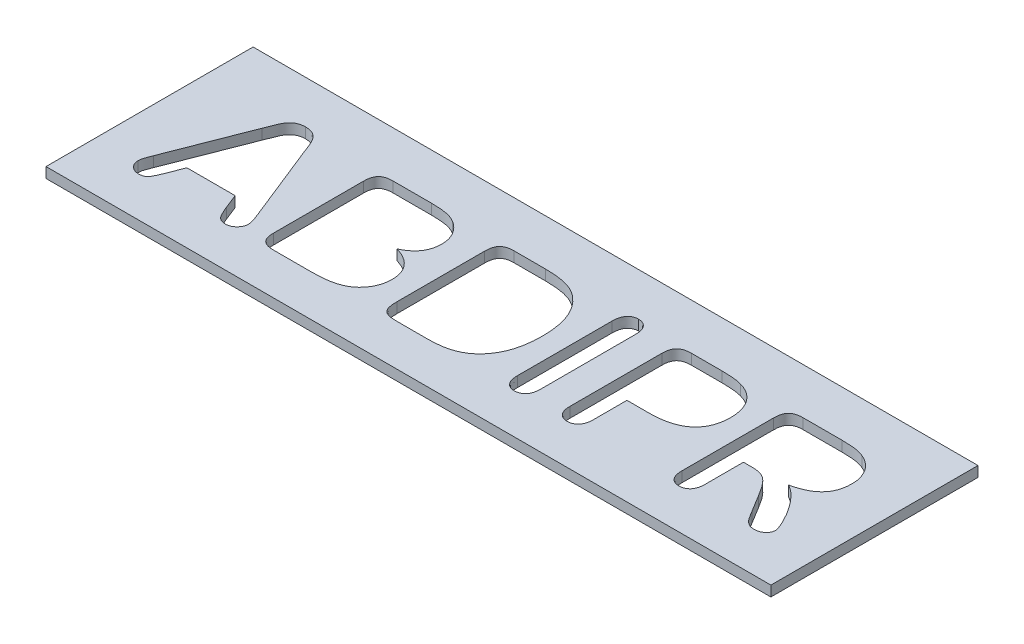
from build123d import *

# Parameters (mm, degrees)
SKETCH1_W           = 35
SKETCH1_H           = 10
BOSS_EXTRUDE1_DEPTH = 0.5
CUT_EXTRUDE4_DEPTH  = 2


with BuildPart() as part:
    # Sketch1 → Boss-Extrude1 (new body)
    with BuildSketch(Plane(origin=(0, 0, 0), x_dir=(1, 0, 0), z_dir=(0, 1, 0))):
        Rectangle(SKETCH1_W, SKETCH1_H)
    extrude(amount=BOSS_EXTRUDE1_DEPTH)

    # Sketch3 → Cut-Extrude4 (cut)
    with BuildSketch(Plane(origin=(0, 0.5, 0), x_dir=(1, 0, 0), z_dir=(0, 1, 0))):
        with BuildLine():
            Line((-11.441015625, -2.349609375), (-11.715234375, -1.65))
            Line((-11.715234375, -1.65), (-14.0484375, -1.65))
            Line((-14.0484375, -1.65), (-14.32265625, -2.36484375))
            add(Edge.make_bspline(
                [(-14.32265625, -2.36484375), (-14.347835962, -2.429152255), (-14.393986303, -2.547019345), (-14.465517251, -2.705100133), (-14.530354862, -2.829674932), (-14.59047857, -2.926424451), (-14.660607879, -2.997756493), (-14.748545347, -3.043456515), (-14.853497882, -3.070371804), (-14.929116363, -3.073387981), (-14.96953125, -3.075)],
                knots=[0, 0, 0, 0, 0.000207167, 0.000379703, 0.000520191, 0.000628424, 0.000720406, 0.000816364, 0.00092182, 0.001042887, 0.001042887, 0.001042887, 0.001042887], degree=3))
            add(Edge.make_bspline(
                [(-14.96953125, -3.075), (-15.005312309, -3.072983598), (-15.075874133, -3.069007165), (-15.177866168, -3.036727284), (-15.273080921, -2.985249355), (-15.359460508, -2.915667549), (-15.432410746, -2.833500255), (-15.485274497, -2.742148574), (-15.519177587, -2.645309748), (-15.52305102, -2.578005721), (-15.525, -2.544140625)],
                knots=[0, 0, 0, 0, 0.000107161, 0.000211326, 0.00031776, 0.000430315, 0.00054243, 0.000645342, 0.000745398, 0.00084673, 0.00084673, 0.00084673, 0.00084673], degree=3))
            add(Edge.make_bspline(
                [(-15.525, -2.544140625), (-15.523193689, -2.503741289), (-15.519483191, -2.420753523), (-15.493089704, -2.316105591), (-15.461401167, -2.225629232), (-15.432122251, -2.143573309), (-15.397345548, -2.048738896), (-15.370506217, -1.981956896), (-15.35625, -1.946484375)],
                knots=[0, 0, 0, 0, 0.000121067, 0.000248693, 0.000321699, 0.000408804, 0.000510028, 0.00062471, 0.00062471, 0.00062471, 0.00062471], degree=3))
            Line((-15.35625, -1.946484375), (-13.887890625, 1.82109375))
            add(Edge.make_bspline(
                [(-13.887890625, 1.82109375), (-13.877033183, 1.849640427), (-13.854390814, 1.909172349), (-13.81718647, 2.002041188), (-13.779422608, 2.103716802), (-13.737887875, 2.210452438), (-13.695622927, 2.317352773), (-13.648036449, 2.416388897), (-13.602120299, 2.507310579), (-13.552270206, 2.588270224), (-13.49796298, 2.661372403), (-13.43572884, 2.725938743), (-13.3651987, 2.782594974), (-13.287981265, 2.833809847), (-13.200946539, 2.874891932), (-13.104314819, 2.90434525), (-12.998298587, 2.921934285), (-12.924288276, 2.923953619), (-12.8859375, 2.925)],
                knots=[0, 0, 0, 0, 9.1624e-05, 0.000191075, 0.000300116, 0.00041698, 0.000534712, 0.000644799, 0.000746483, 0.000840145, 0.000929676, 0.001019185, 0.001108317, 0.001200627, 0.001296557, 0.001395897, 0.00150282, 0.001617813, 0.001617813, 0.001617813, 0.001617813], degree=3))
            add(Edge.make_bspline(
                [(-12.8859375, 2.925), (-12.847191426, 2.923964252), (-12.772395624, 2.921964834), (-12.665292553, 2.904219346), (-12.567931136, 2.875501695), (-12.481665511, 2.833299239), (-12.403893228, 2.783573977), (-12.333122677, 2.727829245), (-12.271563961, 2.663396877), (-12.200252444, 2.568895574), (-12.123532789, 2.440826658), (-12.059347002, 2.302613175), (-12.012806287, 2.180972039), (-11.969275082, 2.076734824), (-11.924501628, 1.957068728), (-11.892603014, 1.87264561), (-11.87578125, 1.828125)],
                knots=[0, 0, 0, 0, 0.000116163, 0.000224243, 0.000324704, 0.000419575, 0.000511251, 0.000601295, 0.000689147, 0.000777745, 0.000956013, 0.001135834, 0.001234194, 0.001346701, 0.001474671, 0.001617453, 0.001617453, 0.001617453, 0.001617453], degree=3))
            Line((-11.87578125, 1.828125), (-10.37578125, -1.91484375))
            add(Edge.make_bspline(
                [(-10.37578125, -1.91484375), (-10.362069188, -1.94919831), (-10.335664466, -2.015353397), (-10.298319026, -2.110858221), (-10.270475505, -2.200435562), (-10.242779562, -2.281190367), (-10.225096723, -2.35601766), (-10.210418027, -2.422642639), (-10.201346416, -2.482167939), (-10.200431427, -2.519504684), (-10.2, -2.537109375)],
                knots=[0, 0, 0, 0, 0.000110982, 0.000213714, 0.000307471, 0.000392341, 0.000469649, 0.00053791, 0.000597075, 0.000649862, 0.000649862, 0.000649862, 0.000649862], degree=3))
            add(Edge.make_bspline(
                [(-10.2, -2.537109375), (-10.202155142, -2.570132184), (-10.206480473, -2.636408348), (-10.238168464, -2.733668106), (-10.293183658, -2.82468516), (-10.364464071, -2.910029077), (-10.450232948, -2.983212519), (-10.54839153, -3.036396381), (-10.654957368, -3.069176662), (-10.729456816, -3.07304225), (-10.7671875, -3.075)],
                knots=[0, 0, 0, 0, 9.9001e-05, 0.000198693, 0.000303207, 0.00041634, 0.000531124, 0.000639146, 0.000749259, 0.000862252, 0.000862252, 0.000862252, 0.000862252], degree=3))
            add(Edge.make_bspline(
                [(-10.7671875, -3.075), (-10.810045817, -3.073116816), (-10.890793668, -3.069568774), (-11.002453245, -3.033539946), (-11.093956784, -2.974673834), (-11.15863903, -2.911722548), (-11.203137979, -2.848941962), (-11.238148472, -2.791272681), (-11.274323764, -2.723100446), (-11.322497594, -2.62112411), (-11.37672123, -2.494818059), (-11.420622538, -2.395667095), (-11.441015625, -2.349609375)],
                knots=[0, 0, 0, 0, 0.000128271, 0.000241671, 0.000347009, 0.00045225, 0.000510148, 0.000577477, 0.000654545, 0.000741556, 0.000915752, 0.001066865, 0.001066865, 0.001066865, 0.001066865], degree=3))
        make_face()
        with BuildLine():
            Line((-6.75703125, -3), (-8.5171875, -3))
            add(Edge.make_bspline(
                [(-8.5171875, -3), (-8.548066158, -2.999684683), (-8.607211026, -2.999080726), (-8.692644647, -2.990770966), (-8.770947545, -2.976754729), (-8.842771247, -2.958217792), (-8.908089191, -2.93471954), (-8.96692833, -2.9061107), (-9.017782509, -2.869904795), (-9.07875055, -2.816360555), (-9.140301939, -2.729140438), (-9.189624937, -2.601657903), (-9.219877565, -2.450216486), (-9.223214212, -2.341173041), (-9.225, -2.2828125)],
                knots=[0, 0, 0, 0, 9.2608e-05, 0.000177381, 0.000257146, 0.000331048, 0.00039963, 0.00046514, 0.000526583, 0.000586337, 0.000707992, 0.000842042, 0.000993957, 0.001168885, 0.001168885, 0.001168885, 0.001168885], degree=3))
            Line((-9.225, -2.2828125), (-9.225, 2.0578125))
            add(Edge.make_bspline(
                [(-9.225, 2.0578125), (-9.223375416, 2.117371055), (-9.220355101, 2.228098226), (-9.188552092, 2.381042192), (-9.138305638, 2.508895247), (-9.062752389, 2.611877256), (-8.960932817, 2.687796753), (-8.834312538, 2.738830555), (-8.683927793, 2.770066267), (-8.575170639, 2.773284318), (-8.5171875, 2.775)],
                knots=[0, 0, 0, 0, 0.000178437, 0.000331738, 0.000466233, 0.00058764, 0.000709751, 0.000842085, 0.000994239, 0.001167997, 0.001167997, 0.001167997, 0.001167997], degree=3))
            Line((-8.5171875, 2.775), (-6.6515625, 2.775))
            add(Edge.make_bspline(
                [(-6.6515625, 2.775), (-6.585147608, 2.774247249), (-6.456546362, 2.772789674), (-6.270794249, 2.763868156), (-6.098739867, 2.74744078), (-5.939206601, 2.724758831), (-5.790298563, 2.691685935), (-5.649474707, 2.649197945), (-5.517714172, 2.591062773), (-5.435171158, 2.544064871), (-5.394140625, 2.520703125)],
                knots=[0, 0, 0, 0, 0.00019925, 0.000385814, 0.000557692, 0.000717622, 0.00086888, 0.001014918, 0.00115818, 0.001299778, 0.001299778, 0.001299778, 0.001299778], degree=3))
            add(Edge.make_bspline(
                [(-5.394140625, 2.520703125), (-5.360161211, 2.499396475), (-5.29220561, 2.456785199), (-5.197222519, 2.382645993), (-5.108971786, 2.299601488), (-5.026233579, 2.210306513), (-4.95099385, 2.114129902), (-4.885128336, 2.012316969), (-4.83023231, 1.904654916), (-4.783065612, 1.793232088), (-4.745153453, 1.677770503), (-4.720148205, 1.558227489), (-4.702342929, 1.436082227), (-4.701045751, 1.353191284), (-4.700390625, 1.311328125)],
                knots=[0, 0, 0, 0, 0.000120264, 0.000240517, 0.000360741, 0.000483481, 0.000605379, 0.000726627, 0.000846651, 0.000967445, 0.001089371, 0.001210505, 0.00133348, 0.001458958, 0.001458958, 0.001458958, 0.001458958], degree=3))
            add(Edge.make_bspline(
                [(-4.700390625, 1.311328125), (-4.702988671, 1.240796002), (-4.708044042, 1.103552116), (-4.750406113, 0.905273758), (-4.818338805, 0.720970725), (-4.915852756, 0.551862405), (-5.040552639, 0.397345857), (-5.194337126, 0.260072678), (-5.37373492, 0.13565648), (-5.50764742, 0.068658714), (-5.576953125, 0.033984375)],
                knots=[0, 0, 0, 0, 0.000211406, 0.000411361, 0.000605302, 0.000798476, 0.000994306, 0.001198394, 0.001414886, 0.001647125, 0.001647125, 0.001647125, 0.001647125], degree=3))
            add(Edge.make_bspline(
                [(-5.576953125, 0.033984375), (-5.530273502, 0.01850607), (-5.439172939, -0.011701592), (-5.308710293, -0.065060268), (-5.186483504, -0.121876895), (-5.073507124, -0.185143227), (-4.970263496, -0.254875067), (-4.874609675, -0.328273429), (-4.789067069, -0.408268175), (-4.712116337, -0.493263322), (-4.644210619, -0.58342165), (-4.584823142, -0.678896049), (-4.536232473, -0.780262552), (-4.493934136, -0.885899675), (-4.464826814, -0.998402007), (-4.440274592, -1.115100833), (-4.428038837, -1.23763197), (-4.42602398, -1.320682894), (-4.425, -1.362890625)],
                knots=[0, 0, 0, 0, 0.000147498, 0.000287859, 0.000422584, 0.000551661, 0.000675819, 0.000796071, 0.000912983, 0.001026655, 0.001139624, 0.001251174, 0.001363332, 0.001476495, 0.001591917, 0.001711426, 0.00183398, 0.00196063, 0.00196063, 0.00196063, 0.00196063], degree=3))
            add(Edge.make_bspline(
                [(-4.425, -1.362890625), (-4.427626881, -1.44089384), (-4.432814111, -1.594924682), (-4.483110744, -1.819042589), (-4.561780312, -2.031773243), (-4.672429347, -2.228892641), (-4.807833827, -2.408638341), (-4.967607701, -2.564839815), (-5.150016922, -2.696405243), (-5.285579599, -2.761004415), (-5.354296875, -2.79375)],
                knots=[0, 0, 0, 0, 0.0002337, 0.000461481, 0.00068546, 0.000912081, 0.001137084, 0.001358345, 0.001580123, 0.001808113, 0.001808113, 0.001808113, 0.001808113], degree=3))
            add(Edge.make_bspline(
                [(-5.354296875, -2.79375), (-5.399754504, -2.812000974), (-5.492589121, -2.849273534), (-5.639572751, -2.893494252), (-5.796443624, -2.92800838), (-5.963359802, -2.956604003), (-6.142283634, -2.975665677), (-6.334601684, -2.989341746), (-6.540910731, -2.999407091), (-6.683580759, -2.999798494), (-6.75703125, -3)],
                knots=[0, 0, 0, 0, 0.000146901, 0.000300005, 0.00045978, 0.000628546, 0.000807782, 0.000999314, 0.001206948, 0.001427273, 0.001427273, 0.001427273, 0.001427273], degree=3))
        make_face()
        with BuildLine():
            Line((-2.6859375, 2.775), (-1.147265625, 2.775))
            add(Edge.make_bspline(
                [(-1.147265625, 2.775), (-1.050750895, 2.77361917), (-0.864535134, 2.770954993), (-0.595997762, 2.751570127), (-0.349102986, 2.717452462), (-0.120663099, 2.671840852), (0.092500353, 2.605420148), (0.294335668, 2.517397132), (0.486016839, 2.404286593), (0.60295242, 2.311947915), (0.662109375, 2.265234375)],
                knots=[0, 0, 0, 0, 0.000289539, 0.000558636, 0.000807066, 0.001036896, 0.001256688, 0.001475506, 0.001696179, 0.001922117, 0.001922117, 0.001922117, 0.001922117], degree=3))
            add(Edge.make_bspline(
                [(0.662109375, 2.265234375), (0.699204557, 2.23204259), (0.773360626, 2.165689706), (0.877526546, 2.059236928), (0.97420917, 1.946074816), (1.063080409, 1.826413034), (1.145281744, 1.700806739), (1.220533689, 1.569000172), (1.28895067, 1.430736631), (1.347729443, 1.284821053), (1.402581568, 1.134012825), (1.447237326, 0.976216153), (1.488225883, 0.813191248), (1.518697841, 0.642687976), (1.545203145, 0.466575533), (1.562176311, 0.283861789), (1.573097822, 0.095057741), (1.574358547, -0.033186992), (1.575, -0.0984375)],
                knots=[0, 0, 0, 0, 0.000149303, 0.000298467, 0.000446421, 0.000595484, 0.000745324, 0.000896491, 0.001050574, 0.001207697, 0.001368192, 0.001531739, 0.001699432, 0.001872275, 0.002051096, 0.002233585, 0.002422552, 0.002618286, 0.002618286, 0.002618286, 0.002618286], degree=3))
            add(Edge.make_bspline(
                [(1.575, -0.0984375), (1.573794855, -0.184006161), (1.571442807, -0.351008177), (1.555405103, -0.596376388), (1.525887303, -0.829812399), (1.486384251, -1.052573716), (1.435093541, -1.264175052), (1.370915117, -1.464887332), (1.293061527, -1.654819682), (1.202701995, -1.834095171), (1.100629294, -2.004458553), (0.983405175, -2.163815899), (0.855141018, -2.31644177), (0.758700791, -2.408659192), (0.71015625, -2.455078125)],
                knots=[0, 0, 0, 0, 0.000256708, 0.000501009, 0.000737208, 0.000962248, 0.001179396, 0.001389897, 0.001593806, 0.001794529, 0.001991686, 0.002188816, 0.002387486, 0.002588847, 0.002588847, 0.002588847, 0.002588847], degree=3))
            add(Edge.make_bspline(
                [(0.71015625, -2.455078125), (0.670808323, -2.487756238), (0.59276456, -2.552570909), (0.46729574, -2.638086397), (0.337301324, -2.714845461), (0.200908362, -2.780164108), (0.059765152, -2.836294246), (-0.085968828, -2.884905991), (-0.237194539, -2.923298904), (-0.39419838, -2.95267784), (-0.558630516, -2.973282528), (-0.732193291, -2.98840301), (-0.916303006, -2.997859007), (-1.042566688, -2.999273465), (-1.107421875, -3)],
                knots=[0, 0, 0, 0, 0.000153368, 0.000304194, 0.000454934, 0.000605883, 0.000757341, 0.000910391, 0.001066431, 0.001225019, 0.00138927, 0.001563375, 0.001747599, 0.001942162, 0.001942162, 0.001942162, 0.001942162], degree=3))
            Line((-1.107421875, -3), (-2.633203125, -3))
            add(Edge.make_bspline(
                [(-2.633203125, -3), (-2.683293312, -2.999225047), (-2.77723658, -2.997771636), (-2.908251776, -2.978207976), (-3.020827368, -2.951188051), (-3.114131747, -2.908026317), (-3.189319084, -2.852952048), (-3.250458451, -2.788830509), (-3.297101361, -2.714732595), (-3.329030277, -2.629666887), (-3.348444949, -2.533803398), (-3.363873799, -2.426199575), (-3.372929583, -2.305618442), (-3.374287517, -2.220717744), (-3.375, -2.176171875)],
                knots=[0, 0, 0, 0, 0.000150114, 0.000281537, 0.000396655, 0.000496265, 0.000587679, 0.000674721, 0.000760557, 0.000848479, 0.000945716, 0.001053439, 0.001174506, 0.001308146, 0.001308146, 0.001308146, 0.001308146], degree=3))
            Line((-3.375, -2.176171875), (-3.375, 2.0578125))
            add(Edge.make_bspline(
                [(-3.375, 2.0578125), (-3.373208148, 2.11656741), (-3.369858826, 2.226391877), (-3.339719242, 2.378565117), (-3.29070443, 2.506457745), (-3.21653605, 2.608767051), (-3.117551938, 2.685414072), (-2.995036312, 2.73910011), (-2.847982054, 2.769962347), (-2.742343971, 2.773246431), (-2.6859375, 2.775)],
                knots=[0, 0, 0, 0, 0.000176097, 0.000329161, 0.000463211, 0.00058392, 0.00070325, 0.000834374, 0.000981947, 0.001151026, 0.001151026, 0.001151026, 0.001151026], degree=3))
        make_face()
        with BuildLine():
            Line((2.625, -2.358984375), (2.625, 2.2125))
            add(Edge.make_bspline(
                [(2.625, 2.2125), (2.626372257, 2.268534342), (2.628947099, 2.373674747), (2.65887973, 2.520292536), (2.705191012, 2.646298707), (2.775330907, 2.747864159), (2.858882217, 2.828196162), (2.956909337, 2.884115843), (3.065500905, 2.920066505), (3.142287861, 2.923328335), (3.181640625, 2.925)],
                knots=[0, 0, 0, 0, 0.00016784, 0.000314928, 0.000447023, 0.000567612, 0.000682013, 0.000791757, 0.000903681, 0.001021343, 0.001021343, 0.001021343, 0.001021343], degree=3))
            add(Edge.make_bspline(
                [(3.181640625, 2.925), (3.222162859, 2.923361853), (3.300865244, 2.920180241), (3.41214605, 2.88414904), (3.511943317, 2.82855475), (3.597693577, 2.74913551), (3.668158131, 2.647775576), (3.716893344, 2.522277833), (3.745841861, 2.374760553), (3.748554739, 2.268897544), (3.75, 2.2125)],
                knots=[0, 0, 0, 0, 0.000121163, 0.000235323, 0.000347101, 0.000461561, 0.000582815, 0.000714253, 0.000862489, 0.0010315, 0.0010315, 0.0010315, 0.0010315], degree=3))
            Line((3.75, 2.2125), (3.75, -2.358984375))
            add(Edge.make_bspline(
                [(3.75, -2.358984375), (3.748566282, -2.415383127), (3.745875072, -2.521248402), (3.716714134, -2.669108291), (3.668099781, -2.795271696), (3.598139431, -2.897981928), (3.511533961, -2.977024753), (3.412747746, -3.034810993), (3.300519327, -3.068262311), (3.222095717, -3.072707127), (3.181640625, -3.075)],
                knots=[0, 0, 0, 0, 0.00016901, 0.000317247, 0.000449772, 0.00057199, 0.000686451, 0.00079881, 0.000912627, 0.001033898, 0.001033898, 0.001033898, 0.001033898], degree=3))
            add(Edge.make_bspline(
                [(3.181640625, -3.075), (3.142749904, -3.07267064), (3.067019935, -3.068134792), (2.958513966, -3.034840225), (2.862545505, -2.975966407), (2.777305392, -2.89685328), (2.706176655, -2.794152097), (2.660632263, -2.666937475), (2.628451723, -2.520345529), (2.626199442, -2.415055894), (2.625, -2.358984375)],
                knots=[0, 0, 0, 0, 0.000116606, 0.000227061, 0.000336391, 0.000451647, 0.000573865, 0.000707052, 0.000854378, 0.001022218, 0.001022218, 0.001022218, 0.001022218], degree=3))
        make_face()
        with BuildLine():
            Line((7.359375, -0.75), (6.3, -0.75))
            Line((6.3, -0.75), (6.3, -2.368359375))
            add(Edge.make_bspline(
                [(6.3, -2.368359375), (6.29865037, -2.422834651), (6.296091572, -2.526115714), (6.2652422, -2.670183826), (6.216669575, -2.795106489), (6.145364996, -2.896517112), (6.059997751, -2.976407479), (5.963163888, -3.034522007), (5.854499391, -3.068193031), (5.77874633, -3.0726904), (5.73984375, -3.075)],
                knots=[0, 0, 0, 0, 0.00016316, 0.00030934, 0.000439692, 0.000562577, 0.000677832, 0.000788169, 0.000898624, 0.00101523, 0.00101523, 0.00101523, 0.00101523], degree=3))
            add(Edge.make_bspline(
                [(5.73984375, -3.075), (5.699400293, -3.072687248), (5.620999236, -3.068203896), (5.508937943, -3.035123568), (5.4109881, -2.976607828), (5.324815484, -2.898467898), (5.255941764, -2.796656723), (5.208699533, -2.672816611), (5.179213967, -2.529502753), (5.17645619, -2.427112203), (5.175, -2.373046875)],
                knots=[0, 0, 0, 0, 0.000121271, 0.000235087, 0.000346434, 0.000460895, 0.000581484, 0.000711398, 0.00085619, 0.00101818, 0.00101818, 0.00101818, 0.00101818], degree=3))
            Line((5.175, -2.373046875), (5.175, 2.061328125))
            add(Edge.make_bspline(
                [(5.175, 2.061328125), (5.175326, 2.09220632), (5.175954525, 2.15173923), (5.184245402, 2.237947887), (5.19814518, 2.31705589), (5.216762086, 2.38978201), (5.241059702, 2.455040586), (5.270780076, 2.513726999), (5.305784318, 2.565747457), (5.361797587, 2.626083745), (5.449096695, 2.689250897), (5.577875048, 2.739853278), (5.731051886, 2.76986248), (5.841252832, 2.773205835), (5.900390625, 2.775)],
                knots=[0, 0, 0, 0, 9.2608e-05, 0.000178547, 0.000259466, 0.000333368, 0.000403456, 0.00046792, 0.000530327, 0.000590869, 0.000714161, 0.000849739, 0.001002802, 0.00118007, 0.00118007, 0.00118007, 0.00118007], degree=3))
            Line((5.900390625, 2.775), (7.369921875, 2.775))
            add(Edge.make_bspline(
                [(7.369921875, 2.775), (7.422664023, 2.775010091), (7.525059934, 2.775029682), (7.67389829, 2.768466252), (7.813367698, 2.760337506), (7.943654943, 2.750601935), (8.064431442, 2.735243653), (8.175705348, 2.716216263), (8.278076971, 2.696041062), (8.34228087, 2.678119244), (8.373046875, 2.66953125)],
                knots=[0, 0, 0, 0, 0.000158207, 0.000307151, 0.000446845, 0.00057735, 0.000699011, 0.000811907, 0.000916019, 0.001011812, 0.001011812, 0.001011812, 0.001011812], degree=3))
            add(Edge.make_bspline(
                [(8.373046875, 2.66953125), (8.431373386, 2.651775877), (8.546114862, 2.61684703), (8.707380779, 2.541218339), (8.858062265, 2.452337636), (8.994731548, 2.345234583), (9.11799016, 2.224738583), (9.225960776, 2.090733108), (9.317803465, 1.943647039), (9.392092467, 1.783400112), (9.452798531, 1.613008843), (9.494072303, 1.431259277), (9.520933822, 1.239476645), (9.523624188, 1.107907437), (9.525, 1.040625)],
                knots=[0, 0, 0, 0, 0.000182696, 0.000359405, 0.000532846, 0.000706545, 0.00087891, 0.001048933, 0.001221596, 0.001397737, 0.001577863, 0.001763197, 0.001955944, 0.002157674, 0.002157674, 0.002157674, 0.002157674], degree=3))
            add(Edge.make_bspline(
                [(9.525, 1.040625), (9.523639944, 0.969441406), (9.520992452, 0.830875104), (9.494270667, 0.62970649), (9.453125864, 0.441306934), (9.39297871, 0.266296959), (9.315551283, 0.104972014), (9.220902953, -0.042832746), (9.109921711, -0.177754192), (8.98145365, -0.298843797), (8.836103572, -0.405856207), (8.674464805, -0.499348035), (8.494831071, -0.575599183), (8.299940545, -0.640791532), (8.087750438, -0.688685124), (7.860062704, -0.725424075), (7.615229659, -0.746190147), (7.446522436, -0.748702314), (7.359375, -0.75)],
                knots=[0, 0, 0, 0, 0.000213439, 0.000415481, 0.000607669, 0.000791115, 0.000969321, 0.001143237, 0.001316389, 0.001492131, 0.001671432, 0.001856759, 0.002050951, 0.002255881, 0.002472485, 0.002702713, 0.002947374, 0.003208797, 0.003208797, 0.003208797, 0.003208797], degree=3))
        make_face()
        with BuildLine():
            Line((12.10546875, -0.525), (11.7, -0.525))
            Line((11.7, -0.525), (11.7, -2.3671875))
            add(Edge.make_bspline(
                [(11.7, -2.3671875), (11.698572444, -2.423972464), (11.695901407, -2.530220255), (11.666941387, -2.678184043), (11.618204871, -2.802976511), (11.549336018, -2.90393262), (11.463990524, -2.980416024), (11.366621919, -3.035790544), (11.256882965, -3.069690448), (11.179539779, -3.073199166), (11.13984375, -3.075)],
                knots=[0, 0, 0, 0, 0.00017018, 0.000318417, 0.000449855, 0.000569478, 0.000681495, 0.000790655, 0.000903351, 0.001022179, 0.001022179, 0.001022179, 0.001022179], degree=3))
            add(Edge.make_bspline(
                [(11.13984375, -3.075), (11.097419425, -3.072847061), (11.015769314, -3.068703501), (10.900783826, -3.034322246), (10.801478575, -2.976118471), (10.717621239, -2.896018404), (10.65254807, -2.792486711), (10.60773047, -2.667792628), (10.579406988, -2.52313387), (10.576526661, -2.419678338), (10.575, -2.36484375)],
                knots=[0, 0, 0, 0, 0.000127104, 0.000244625, 0.000355972, 0.000469523, 0.000589151, 0.000719314, 0.000865023, 0.001029353, 0.001029353, 0.001029353, 0.001029353], degree=3))
            Line((10.575, -2.36484375), (10.575, 2.061328125))
            add(Edge.make_bspline(
                [(10.575, 2.061328125), (10.576717433, 2.119700782), (10.579939967, 2.229229306), (10.611185323, 2.380758993), (10.661991643, 2.508002941), (10.737132998, 2.610363541), (10.838271675, 2.686760864), (10.963899667, 2.7389316), (11.114124036, 2.770093303), (11.22249019, 2.773289797), (11.28046875, 2.775)],
                knots=[0, 0, 0, 0, 0.000174928, 0.000328228, 0.000461642, 0.000583049, 0.000704229, 0.000837023, 0.000988032, 0.001161789, 0.001161789, 0.001161789, 0.001161789], degree=3))
            Line((11.28046875, 2.775), (13.15078125, 2.775))
            add(Edge.make_bspline(
                [(13.15078125, 2.775), (13.21289178, 2.774430966), (13.332453914, 2.773335582), (13.50526269, 2.768342035), (13.663881101, 2.75614996), (13.81016602, 2.74123347), (13.946041381, 2.721250507), (14.073420863, 2.689764053), (14.19478395, 2.652351796), (14.27099611, 2.618341), (14.30859375, 2.6015625)],
                knots=[0, 0, 0, 0, 0.000186343, 0.000358708, 0.000518513, 0.000663457, 0.000799863, 0.000930042, 0.001056788, 0.001180198, 0.001180198, 0.001180198, 0.001180198], degree=3))
            add(Edge.make_bspline(
                [(14.30859375, 2.6015625), (14.353582506, 2.581367881), (14.443038172, 2.541212889), (14.569212555, 2.464904163), (14.687701522, 2.377402182), (14.796574168, 2.27704196), (14.896674058, 2.168008704), (14.981985979, 2.047080162), (15.056486904, 1.919163218), (15.117376597, 1.782717936), (15.164813632, 1.640079538), (15.200936101, 1.492909041), (15.220597728, 1.341161353), (15.223525056, 1.23872317), (15.225, 1.187109375)],
                knots=[0, 0, 0, 0, 0.000147824, 0.000293932, 0.000441356, 0.000589003, 0.000737517, 0.000884507, 0.001032042, 0.001181013, 0.001331839, 0.001482483, 0.001634962, 0.00178981, 0.00178981, 0.00178981, 0.00178981], degree=3))
            add(Edge.make_bspline(
                [(15.225, 1.187109375), (15.223956718, 1.134710524), (15.221918474, 1.03233966), (15.203643115, 0.883074123), (15.175810889, 0.741460512), (15.136781622, 0.607451297), (15.082764636, 0.482536927), (15.020094294, 0.36509985), (14.945217241, 0.255719379), (14.858281951, 0.154807046), (14.758988282, 0.062219159), (14.648880411, -0.024102067), (14.527204838, -0.103775569), (14.392676981, -0.174943092), (14.246708981, -0.239839169), (14.088394073, -0.296014466), (13.919210071, -0.349045565), (13.801009462, -0.37547388), (13.740234375, -0.3890625)],
                knots=[0, 0, 0, 0, 0.000157141, 0.000307003, 0.000450413, 0.000589822, 0.000724771, 0.000857953, 0.000988621, 0.001121576, 0.001256708, 0.001395257, 0.001540871, 0.001692388, 0.001851353, 0.002019655, 0.002196107, 0.002382851, 0.002382851, 0.002382851, 0.002382851], degree=3))
            add(Edge.make_bspline(
                [(13.740234375, -0.3890625), (13.79292272, -0.418377195), (13.900356973, -0.47815137), (14.051545518, -0.592267678), (14.200943792, -0.723024412), (14.342711005, -0.874546899), (14.480454086, -1.036097603), (14.613490676, -1.203536232), (14.737564197, -1.376988341), (14.851914813, -1.553777857), (14.957696081, -1.727533907), (15.051828616, -1.895064714), (15.132527888, -2.054490042), (15.201102073, -2.202550151), (15.255725211, -2.334695195), (15.29464115, -2.446540109), (15.32078646, -2.535205559), (15.325961842, -2.587787791), (15.328125, -2.609765625)],
                knots=[0, 0, 0, 0, 0.000180685, 0.000368427, 0.000566862, 0.000775738, 0.000990169, 0.001203753, 0.001417086, 0.001629661, 0.00183526, 0.00202728, 0.002205994, 0.002371162, 0.002516748, 0.002634602, 0.002726696, 0.002792832, 0.002792832, 0.002792832, 0.002792832], degree=3))
            add(Edge.make_bspline(
                [(15.328125, -2.609765625), (15.324125295, -2.647854808), (15.315732853, -2.727776019), (15.267091456, -2.819838995), (15.215627871, -2.88814697), (15.169393443, -2.936272179), (15.115043829, -2.976686273), (15.055177829, -3.012206027), (14.989452575, -3.040447539), (14.918047472, -3.059972171), (14.841935479, -3.073756183), (14.789127661, -3.074579012), (14.762109375, -3.075)],
                knots=[0, 0, 0, 0, 0.000114052, 0.000239311, 0.000305405, 0.000370873, 0.000438609, 0.000507948, 0.000579346, 0.000652426, 0.000729681, 0.000810617, 0.000810617, 0.000810617, 0.000810617], degree=3))
            add(Edge.make_bspline(
                [(14.762109375, -3.075), (14.730363844, -3.074013211), (14.669082615, -3.072108326), (14.581305905, -3.053551114), (14.500490575, -3.026265313), (14.404732348, -2.971480774), (14.299157737, -2.881822304), (14.209703896, -2.771237632), (14.140710982, -2.666718462), (14.080582693, -2.570631621), (14.009349084, -2.4593372), (13.960731362, -2.378643657), (13.934765625, -2.335546875)],
                knots=[0, 0, 0, 0, 9.5103e-05, 0.000183585, 0.00026809, 0.000349929, 0.000513026, 0.000680325, 0.000774906, 0.000888693, 0.001020366, 0.001171301, 0.001171301, 0.001171301, 0.001171301], degree=3))
            Line((13.934765625, -2.335546875), (13.463671875, -1.5609375))
            add(Edge.make_bspline(
                [(13.463671875, -1.5609375), (13.423505822, -1.493859772), (13.347549278, -1.367011552), (13.233030958, -1.191673515), (13.123964177, -1.042502158), (13.021449434, -0.916180488), (12.921832187, -0.81080994), (12.822440921, -0.724059369), (12.720671633, -0.656920186), (12.617196321, -0.60419734), (12.506011395, -0.567742651), (12.384209539, -0.542248642), (12.249208257, -0.527153671), (12.154727521, -0.525738052), (12.10546875, -0.525)],
                knots=[0, 0, 0, 0, 0.000234542, 0.000443534, 0.000627999, 0.0007887, 0.000931264, 0.001062567, 0.001183474, 0.001296151, 0.00140992, 0.001533345, 0.001668969, 0.0018167, 0.0018167, 0.0018167, 0.0018167], degree=3))
        make_face()
    extrude(amount=-CUT_EXTRUDE4_DEPTH, mode=Mode.SUBTRACT)


solid = part.part
